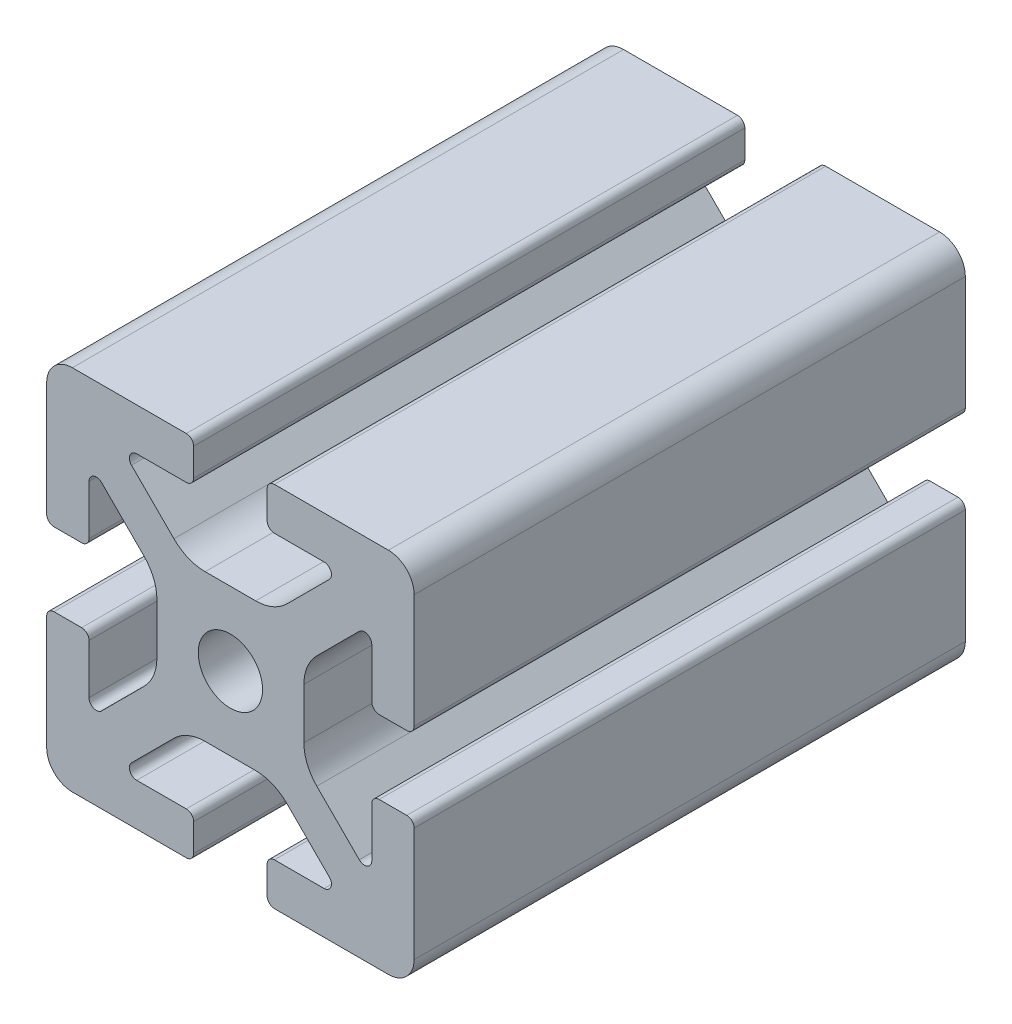
from build123d import *

# Parameters (mm, degrees)
BOSS_EXTRUDE1_DEPTH = 30


with BuildPart() as part:
    # Sketch4 → Boss-Extrude1 (new body, symmetric)
    with BuildSketch(Plane.XY):
        with BuildLine():
            Line((4.8, -20), (17.2, -20))
            ThreePointArc((17.2, -20), (19.179898987, -19.179898987), (20, -17.2))
            Line((20, -17.2), (20, -4.8))
            ThreePointArc((20, -4.8), (19.765685425, -4.234314575), (19.2, -4))
            Line((19.2, -4), (16.190663761, -4))
            ThreePointArc((16.190663761, -4), (15.624978336, -4.234314575), (15.390663761, -4.8))
            Line((15.390663761, -4.8), (15.390663761, -10.2))
            ThreePointArc((15.390663761, -10.2), (14.896810507, -10.939103626), (14.024978336, -10.765685425))
            Line((14.024978336, -10.765685425), (9.40588745, -6.146594539))
            ThreePointArc((9.40588745, -6.146594539), (8.365378244, -4.589362465), (8, -2.752481989))
            Line((8, -2.752481989), (8, 0))
            Line((8, 0), (3.5, 0))
            ThreePointArc((3.5, 0), (2.474873734, -2.474873734), (0, -3.5))
            Line((0, -3.5), (0, -8))
            Line((0, -8), (2.752481989, -8))
            ThreePointArc((2.752481989, -8), (4.589362465, -8.365378244), (6.146594539, -9.40588745))
            Line((6.146594539, -9.40588745), (10.765685425, -14.024978336))
            ThreePointArc((10.765685425, -14.024978336), (10.939103626, -14.896810507), (10.2, -15.390663761))
            Line((10.2, -15.390663761), (4.8, -15.390663761))
            ThreePointArc((4.8, -15.390663761), (4.234314575, -15.624978336), (4, -16.190663761))
            Line((4, -16.190663761), (4, -19.2))
            ThreePointArc((4, -19.2), (4.234314575, -19.765685425), (4.8, -20))
        make_face()
    extrude(amount=BOSS_EXTRUDE1_DEPTH, both=True)

    # Mirror1: part across plane


with BuildPart() as part_1:
    add(part.part)
    add(part.part.mirror(Plane(origin=(0, 0, 0), x_dir=(0, 0, 1), z_dir=(1, 0, 0))))

    # Mirror2: part across plane


with BuildPart() as part_2:
    add(part_1.part)
    add(part_1.part.mirror(Plane.ZX))


solid = part_2.part
